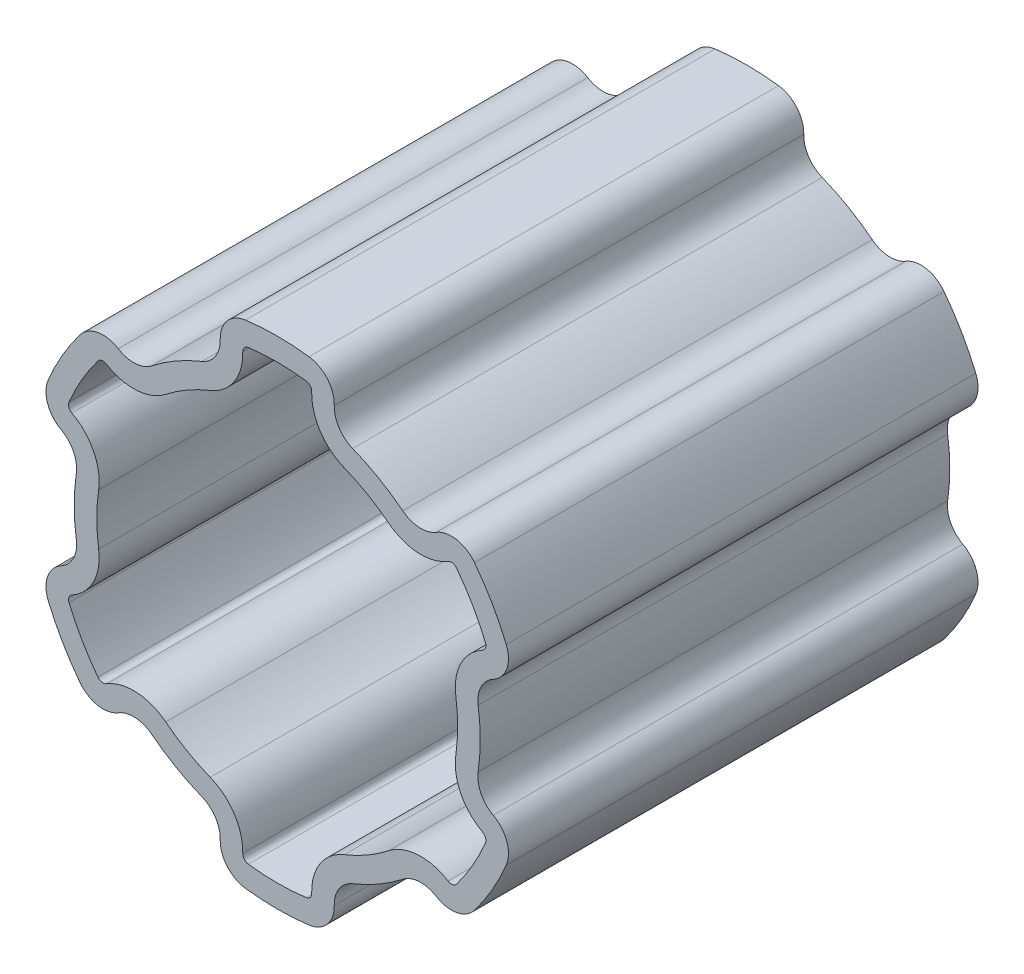
from build123d import *

# Parameters (mm, degrees)
BOSS_EXTRUDE1_DEPTH = 33.02


with BuildPart() as part:
    # Sketch1 → Boss-Extrude1 (new body)
    with BuildSketch(Plane.XY):
        with BuildLine():
            ThreePointArc((-5.305232227, 13.252552057), (-7.1375, 12.362512639), (-8.824430633, 11.22074191))
            ThreePointArc((-8.824430633, 11.22074191), (-9.981957879, 10.782799599), (-11.181776449, 11.08627644))
            ThreePointArc((-11.181776449, 11.08627644), (-12.622148396, 11.355295802), (-13.870578082, 10.588180375))
            ThreePointArc((-13.870578082, 10.588180375), (-15.112143296, 8.725), (-16.104922226, 6.718182797))
            ThreePointArc((-16.104922226, 6.718182797), (-16.145048829, 5.25345326), (-15.191885255, 4.140564245))
            ThreePointArc((-15.191885255, 4.140564245), (-14.329157316, 3.253229304), (-14.12966286, 2.031810147))
            ThreePointArc((-14.12966286, 2.031810147), (-14.238619356, 1.01850078), (-14.275, 0))
            ThreePointArc((-14.275, 0), (-14.238619356, -1.01850078), (-14.12966286, -2.031810147))
            ThreePointArc((-14.12966286, -2.031810147), (-14.329157316, -3.253229304), (-15.191885255, -4.140564245))
            ThreePointArc((-15.191885255, -4.140564245), (-16.145048829, -5.25345326), (-16.104922226, -6.718182797))
            ThreePointArc((-16.104922226, -6.718182797), (-15.112143296, -8.725), (-13.870578082, -10.588180375))
            ThreePointArc((-13.870578082, -10.588180375), (-12.622148396, -11.355295802), (-11.181776449, -11.08627644))
            ThreePointArc((-11.181776449, -11.08627644), (-9.981957879, -10.782799599), (-8.824430633, -11.22074191))
            ThreePointArc((-8.824430633, -11.22074191), (-7.1375, -12.362512639), (-5.305232227, -13.252552057))
            ThreePointArc((-5.305232227, -13.252552057), (-4.347199437, -14.036028902), (-4.010108806, -15.226840684))
            ThreePointArc((-4.010108806, -15.226840684), (-3.522900434, -16.608749062), (-2.234344144, -17.306363172))
            ThreePointArc((-2.234344144, -17.306363172), (0, -17.45), (2.234344144, -17.306363172))
            ThreePointArc((2.234344144, -17.306363172), (3.503647323, -16.630968906), (4.010957256, -15.285634521))
            ThreePointArc((4.010957256, -15.285634521), (4.010745132, -15.256234542), (4.010108806, -15.226840684))
            ThreePointArc((4.010108806, -15.226840684), (4.009464671, -15.197086165), (4.009249945, -15.167325448))
            ThreePointArc((4.009249945, -15.167325448), (4.363702952, -14.011262386), (5.305232227, -13.252552057))
            ThreePointArc((5.305232227, -13.252552057), (7.1375, -12.362512639), (8.824430633, -11.22074191))
            ThreePointArc((8.824430633, -11.22074191), (9.981957879, -10.782799599), (11.181776449, -11.08627644))
            ThreePointArc((11.181776449, -11.08627644), (12.622148396, -11.355295802), (13.870578082, -10.588180375))
            ThreePointArc((13.870578082, -10.588180375), (15.112143296, -8.725), (16.104922226, -6.718182797))
            ThreePointArc((16.104922226, -6.718182797), (16.2223271, -6.333751864), (16.261976436, -5.933753144))
            ThreePointArc((16.261976436, -5.933753144), (15.974119502, -4.889648077), (15.191885255, -4.140564245))
            ThreePointArc((15.191885255, -4.140564245), (14.400052997, -3.382289157), (14.10866406, -2.325372926))
            ThreePointArc((14.10866406, -2.325372926), (14.113920458, -2.1782165), (14.12966286, -2.031810147))
            ThreePointArc((14.12966286, -2.031810147), (14.275, 0), (14.12966286, 2.031810147))
            ThreePointArc((14.12966286, 2.031810147), (14.113920458, 2.1782165), (14.10866406, 2.325372926))
            ThreePointArc((14.10866406, 2.325372926), (14.400052997, 3.382289157), (15.191885255, 4.140564245))
            ThreePointArc((15.191885255, 4.140564245), (15.974119502, 4.889648077), (16.261976436, 5.933753144))
            ThreePointArc((16.261976436, 5.933753144), (16.2223271, 6.333751864), (16.104922226, 6.718182797))
            ThreePointArc((16.104922226, 6.718182797), (15.112143296, 8.725), (13.870578082, 10.588180375))
            ThreePointArc((13.870578082, 10.588180375), (12.622148396, 11.355295802), (11.181776449, 11.08627644))
            ThreePointArc((11.181776449, 11.08627644), (9.981957879, 10.782799599), (8.824430633, 11.22074191))
            ThreePointArc((8.824430633, 11.22074191), (7.1375, 12.362512639), (5.305232227, 13.252552057))
            ThreePointArc((5.305232227, 13.252552057), (4.363702952, 14.011262386), (4.009249945, 15.167325448))
            ThreePointArc((4.009249945, 15.167325448), (4.009464671, 15.197086165), (4.010108806, 15.226840684))
            ThreePointArc((4.010108806, 15.226840684), (4.010745132, 15.256234542), (4.010957256, 15.285634521))
            ThreePointArc((4.010957256, 15.285634521), (3.503647323, 16.630968906), (2.234344144, 17.306363172))
            ThreePointArc((2.234344144, 17.306363172), (0, 17.45), (-2.234344144, 17.306363172))
            ThreePointArc((-2.234344144, 17.306363172), (-3.522900434, 16.608749062), (-4.010108806, 15.226840684))
            ThreePointArc((-4.010108806, 15.226840684), (-4.347199437, 14.036028902), (-5.305232227, 13.252552057))
        make_face()
        with BuildLine():
            ThreePointArc((-4.715245806, 11.778756863), (-6.34375, 10.987697311), (-7.843079766, 9.972901084))
            ThreePointArc((-7.843079766, 9.972901084), (-9.891552176, 9.197875923), (-12.014867411, 9.734937956))
            ThreePointArc((-12.014867411, 9.734937956), (-12.332986369, 9.794353275), (-12.608713171, 9.624929009))
            ThreePointArc((-12.608713171, 9.624929009), (-13.737327968, 7.93125), (-14.639789617, 6.107001411))
            ThreePointArc((-14.639789617, 6.107001411), (-14.648651934, 5.783502863), (-14.438137279, 5.537711424))
            ThreePointArc((-14.438137279, 5.537711424), (-12.911370298, 3.967397506), (-12.558325571, 1.805855779))
            ThreePointArc((-12.558325571, 1.805855779), (-12.655165189, 0.905234932), (-12.6875, 0))
            ThreePointArc((-12.6875, 0), (-12.655165189, -0.905234932), (-12.558325571, -1.805855779))
            ThreePointArc((-12.558325571, -1.805855779), (-12.911370298, -3.967397506), (-14.438137279, -5.537711424))
            ThreePointArc((-14.438137279, -5.537711424), (-14.648651934, -5.783502863), (-14.639789617, -6.107001411))
            ThreePointArc((-14.639789617, -6.107001411), (-13.737327968, -7.93125), (-12.608713171, -9.624929009))
            ThreePointArc((-12.608713171, -9.624929009), (-12.332986369, -9.794353275), (-12.014867411, -9.734937956))
            ThreePointArc((-12.014867411, -9.734937956), (-9.891552176, -9.197875923), (-7.843079766, -9.972901084))
            ThreePointArc((-7.843079766, -9.972901084), (-6.34375, -10.987697311), (-4.715245806, -11.778756863))
            ThreePointArc((-4.715245806, -11.778756863), (-3.019818122, -13.165273429), (-2.423269868, -15.272649379))
            ThreePointArc((-2.423269868, -15.272649379), (-2.315665565, -15.577856137), (-2.031076446, -15.731930419))
            ThreePointArc((-2.031076446, -15.731930419), (0, -15.8625), (2.031076446, -15.731930419))
            ThreePointArc((2.031076446, -15.731930419), (2.311413344, -15.582763588), (2.423457256, -15.285634521))
            ThreePointArc((2.423457256, -15.285634521), (2.423410406, -15.279141274), (2.423269868, -15.272649379))
            ThreePointArc((2.423269868, -15.272649379), (2.422129945, -15.219992897), (2.421749945, -15.167325448))
            ThreePointArc((2.421749945, -15.167325448), (3.049024342, -13.1214442), (4.715245806, -11.778756863))
            ThreePointArc((4.715245806, -11.778756863), (6.34375, -10.987697311), (7.843079766, -9.972901084))
            ThreePointArc((7.843079766, -9.972901084), (9.891552176, -9.197875923), (12.014867411, -9.734937956))
            ThreePointArc((12.014867411, -9.734937956), (12.332986369, -9.794353275), (12.608713171, -9.624929009))
            ThreePointArc((12.608713171, -9.624929009), (13.737327968, -7.93125), (14.639789617, -6.107001411))
            ThreePointArc((14.639789617, -6.107001411), (14.665719527, -6.022096419), (14.674476436, -5.933753144))
            ThreePointArc((14.674476436, -5.933753144), (14.610900672, -5.703153252), (14.438137279, -5.537711424))
            ThreePointArc((14.438137279, -5.537711424), (13.036834166, -4.195794332), (12.52116406, -2.325372926))
            ThreePointArc((12.52116406, -2.325372926), (12.530466291, -2.064950652), (12.558325571, -1.805855779))
            ThreePointArc((12.558325571, -1.805855779), (12.6875, 0), (12.558325571, 1.805855779))
            ThreePointArc((12.558325571, 1.805855779), (12.530466291, 2.064950652), (12.52116406, 2.325372926))
            ThreePointArc((12.52116406, 2.325372926), (13.036834166, 4.195794332), (14.438137279, 5.537711424))
            ThreePointArc((14.438137279, 5.537711424), (14.610900672, 5.703153252), (14.674476436, 5.933753144))
            ThreePointArc((14.674476436, 5.933753144), (14.665719527, 6.022096419), (14.639789617, 6.107001411))
            ThreePointArc((14.639789617, 6.107001411), (13.737327968, 7.93125), (12.608713171, 9.624929009))
            ThreePointArc((12.608713171, 9.624929009), (12.332986369, 9.794353275), (12.014867411, 9.734937956))
            ThreePointArc((12.014867411, 9.734937956), (9.891552176, 9.197875923), (7.843079766, 9.972901084))
            ThreePointArc((7.843079766, 9.972901084), (6.34375, 10.987697311), (4.715245806, 11.778756863))
            ThreePointArc((4.715245806, 11.778756863), (3.049024342, 13.1214442), (2.421749945, 15.167325448))
            ThreePointArc((2.421749945, 15.167325448), (2.422129945, 15.219992897), (2.423269868, 15.272649379))
            ThreePointArc((2.423269868, 15.272649379), (2.423410406, 15.279141274), (2.423457256, 15.285634521))
            ThreePointArc((2.423457256, 15.285634521), (2.311413344, 15.582763588), (2.031076446, 15.731930419))
            ThreePointArc((2.031076446, 15.731930419), (0, 15.8625), (-2.031076446, 15.731930419))
            ThreePointArc((-2.031076446, 15.731930419), (-2.315665565, 15.577856137), (-2.423269868, 15.272649379))
            ThreePointArc((-2.423269868, 15.272649379), (-3.019818122, 13.165273429), (-4.715245806, 11.778756863))
        make_face(mode=Mode.SUBTRACT)
    extrude(amount=BOSS_EXTRUDE1_DEPTH)


solid = part.part
